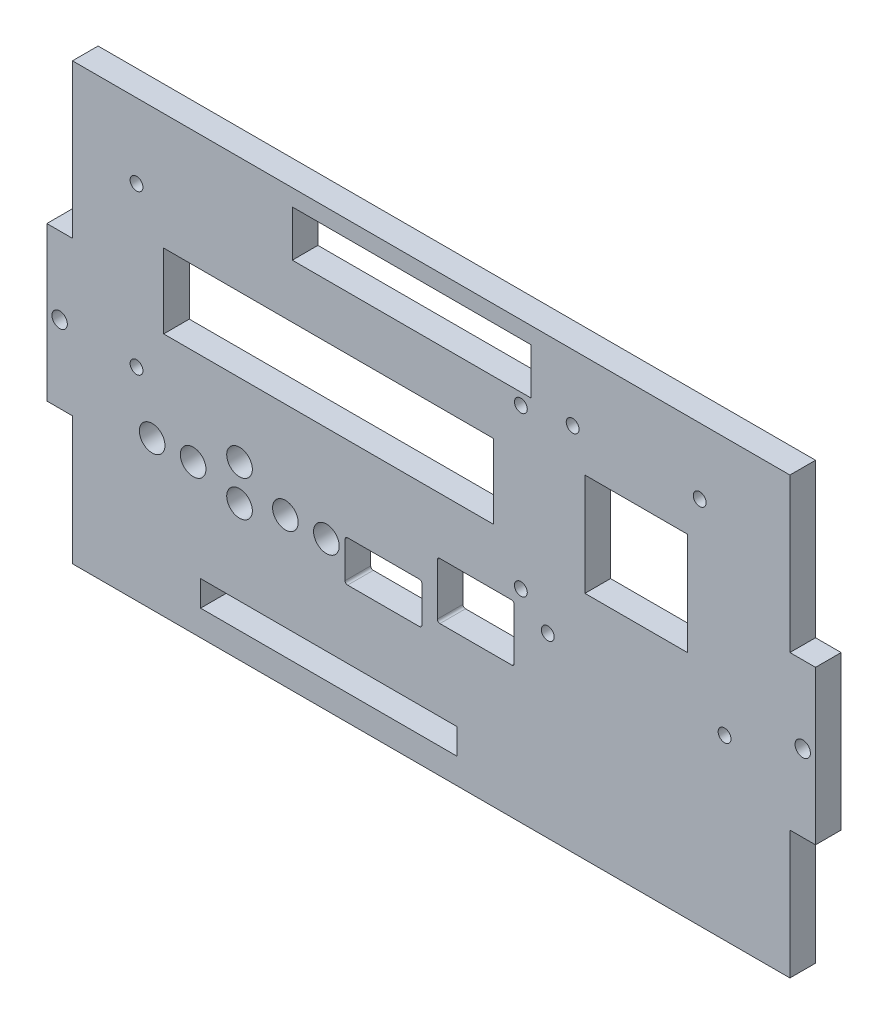
from build123d import *

# Parameters (mm, degrees)
BOSS_EXTRUDE1_DEPTH = 5
SKETCH2_R           = 1.25
SKETCH2_W           = 64.4
SKETCH2_H           = 14.51
SKETCH2_W_2         = 20
SKETCH2_H_2         = 20
CUT_EXTRUDE1_DEPTH  = 5
SKETCH3_R           = 2.5
SKETCH3_R_2         = 1.5
SKETCH3_W           = 46.6
SKETCH3_H           = 9
SKETCH3_W_2         = 15
SKETCH3_H_2         = 8
SKETCH3_H_3         = 11
SKETCH3_W_3         = 50
SKETCH3_H_4         = 5
CUT_EXTRUDE2_DEPTH  = 10
FILLET1_R           = 0.5


with BuildPart() as part:
    # Sketch1 → Boss-Extrude1 (new body)
    with BuildSketch(Plane.XY):
        Polygon((-75, -15), (-70, -15), (-70, -40), (70, -40), (70, -15), (75, -15), (75, 15), (70, 15), (70, 45), (-70, 45), (-70, 15), (-75, 15), align=None)
    extrude(amount=BOSS_EXTRUDE1_DEPTH)

    # Sketch2 → Cut-Extrude1 (cut)
    with BuildSketch(Plane.XY.offset(5)):
        with Locations((-57.5, 30.5)):
            Circle(SKETCH2_R)
        with Locations((17.5, 30.5)):
            Circle(SKETCH2_R)
        with Locations((17.5, -0.5)):
            Circle(SKETCH2_R)
        with Locations((-57.5, -0.5)):
            Circle(SKETCH2_R)
        with Locations((27.6, 32.132337083)):
            Circle(SKETCH2_R)
        with Locations((52.4, 32.132337083)):
            Circle(SKETCH2_R)
        with Locations((22.75, -5.367662917)):
            Circle(SKETCH2_R)
        with Locations((57.25, -5.367662917)):
            Circle(SKETCH2_R)
        with Locations((-20, 15)):
            Rectangle(SKETCH2_W, SKETCH2_H)
        with Locations((40, 15)):
            Rectangle(SKETCH2_W_2, SKETCH2_H_2)
    extrude(amount=-CUT_EXTRUDE1_DEPTH, mode=Mode.SUBTRACT)

    # Sketch3 → Cut-Extrude2 (cut)
    with BuildSketch(Plane.XY.offset(5)):
        with Locations((-54.45, -11)):
            Circle(SKETCH3_R)
        with Locations((-46.45, -11)):
            Circle(SKETCH3_R)
        with Locations((-37.4, -6.5)):
            Circle(SKETCH3_R)
        with Locations((-28.45, -11)):
            Circle(SKETCH3_R)
        with Locations((-20.45, -11)):
            Circle(SKETCH3_R)
        with Locations((72.5, 0)):
            Circle(SKETCH3_R_2)
        with Locations((-72.5, 0)):
            Circle(SKETCH3_R_2)
        with Locations((-37.4, -13.5)):
            Circle(SKETCH3_R)
        with Locations((-3.8, 37.255)):
            Rectangle(SKETCH3_W, SKETCH3_H)
        with Locations((-9.3, -12.755)):
            Rectangle(SKETCH3_W_2, SKETCH3_H_2)
        with Locations((8.7, -8.755)):
            Rectangle(SKETCH3_W_2, SKETCH3_H_3)
        with Locations((-20, -32.5)):
            Rectangle(SKETCH3_W_3, SKETCH3_H_4)
    extrude(amount=-CUT_EXTRUDE2_DEPTH, mode=Mode.SUBTRACT)

    # Fillet1
    fillet1_edges = [part.edges().sort_by_distance(p)[0] for p in [
        (16.2, -3.255, 2.5),
        (16.2, -14.255, 2.5),
        (1.2, -14.255, 2.5),
        (1.2, -3.255, 2.5),
        (-1.8, -8.755, 2.5),
        (-1.8, -16.755, 2.5),
        (-16.8, -16.755, 2.5),
        (-16.8, -8.755, 2.5),
    ]]
    fillet(fillet1_edges, radius=FILLET1_R)


solid = part.part
